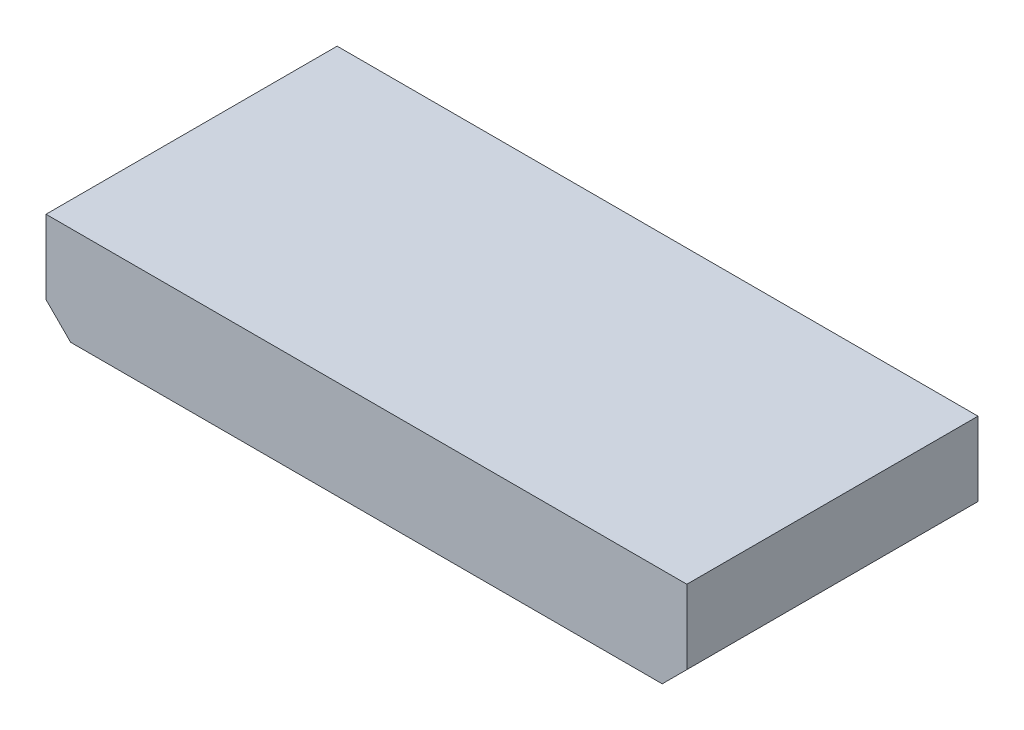
from build123d import *

# Parameters (mm, degrees)
COMPONENT_OUTLINE_DEPTH = 15
SKETCH2_R               = 0.25
EXTRUDE_1_DEPTH         = 2
SKETCH3_R               = 0.25
EXTRUDE_2_DEPTH         = 2
SKETCH4_R               = 0.25
EXTRUDE_3_DEPTH         = 2
SKETCH5_R               = 0.25
EXTRUDE_4_DEPTH         = 2
SKETCH6_R               = 0.25
EXTRUDE_5_DEPTH         = 2
SKETCH7_R               = 0.25
EXTRUDE_6_DEPTH         = 2
SKETCH8_R               = 0.25
EXTRUDE_7_DEPTH         = 2
SKETCH9_R               = 0.25
EXTRUDE_8_DEPTH         = 2
SKETCH10_R              = 0.25
EXTRUDE_9_DEPTH         = 2
SKETCH11_R              = 0.25
EXTRUDE_10_DEPTH        = 2


with BuildPart() as part:
    # Sketch1 → Component_Outline (new body)
    with BuildSketch(Plane.XY):
        Polygon((-5.08, 2.54), (-5.08, -1.27), (-3.81, -2.54), (26.67, -2.54), (27.94, -1.27), (27.94, 2.54), align=None)
    extrude(amount=COMPONENT_OUTLINE_DEPTH)


with BuildPart() as body_2:
    # Sketch2 → Extrude 1 (new body)
    with BuildSketch(Plane.XY):
        Circle(SKETCH2_R)
    extrude(amount=-EXTRUDE_1_DEPTH)


with BuildPart() as body_3:
    # Sketch3 → Extrude 2 (new body)
    with BuildSketch(Plane.XY):
        with Locations((2.54, 0)):
            Circle(SKETCH3_R)
    extrude(amount=-EXTRUDE_2_DEPTH)


with BuildPart() as body_4:
    # Sketch4 → Extrude 3 (new body)
    with BuildSketch(Plane.XY):
        with Locations((5.08, 0)):
            Circle(SKETCH4_R)
    extrude(amount=-EXTRUDE_3_DEPTH)


with BuildPart() as body_5:
    # Sketch5 → Extrude 4 (new body)
    with BuildSketch(Plane.XY):
        with Locations((7.62, 0)):
            Circle(SKETCH5_R)
    extrude(amount=-EXTRUDE_4_DEPTH)


with BuildPart() as body_6:
    # Sketch6 → Extrude 5 (new body)
    with BuildSketch(Plane.XY):
        with Locations((10.16, 0)):
            Circle(SKETCH6_R)
    extrude(amount=-EXTRUDE_5_DEPTH)


with BuildPart() as body_7:
    # Sketch7 → Extrude 6 (new body)
    with BuildSketch(Plane.XY):
        with Locations((12.7, 0)):
            Circle(SKETCH7_R)
    extrude(amount=-EXTRUDE_6_DEPTH)


with BuildPart() as body_8:
    # Sketch8 → Extrude 7 (new body)
    with BuildSketch(Plane.XY):
        with Locations((15.24, 0)):
            Circle(SKETCH8_R)
    extrude(amount=-EXTRUDE_7_DEPTH)


with BuildPart() as body_9:
    # Sketch9 → Extrude 8 (new body)
    with BuildSketch(Plane.XY):
        with Locations((17.78, 0)):
            Circle(SKETCH9_R)
    extrude(amount=-EXTRUDE_8_DEPTH)


with BuildPart() as body_10:
    # Sketch10 → Extrude 9 (new body)
    with BuildSketch(Plane.XY):
        with Locations((20.32, 0)):
            Circle(SKETCH10_R)
    extrude(amount=-EXTRUDE_9_DEPTH)


with BuildPart() as body_11:
    # Sketch11 → Extrude 10 (new body)
    with BuildSketch(Plane.XY):
        with Locations((22.86, 0)):
            Circle(SKETCH11_R)
    extrude(amount=-EXTRUDE_10_DEPTH)


solid = Compound([part.part, body_2.part, body_3.part, body_4.part, body_5.part, body_6.part, body_7.part, body_8.part, body_9.part, body_10.part, body_11.part])
